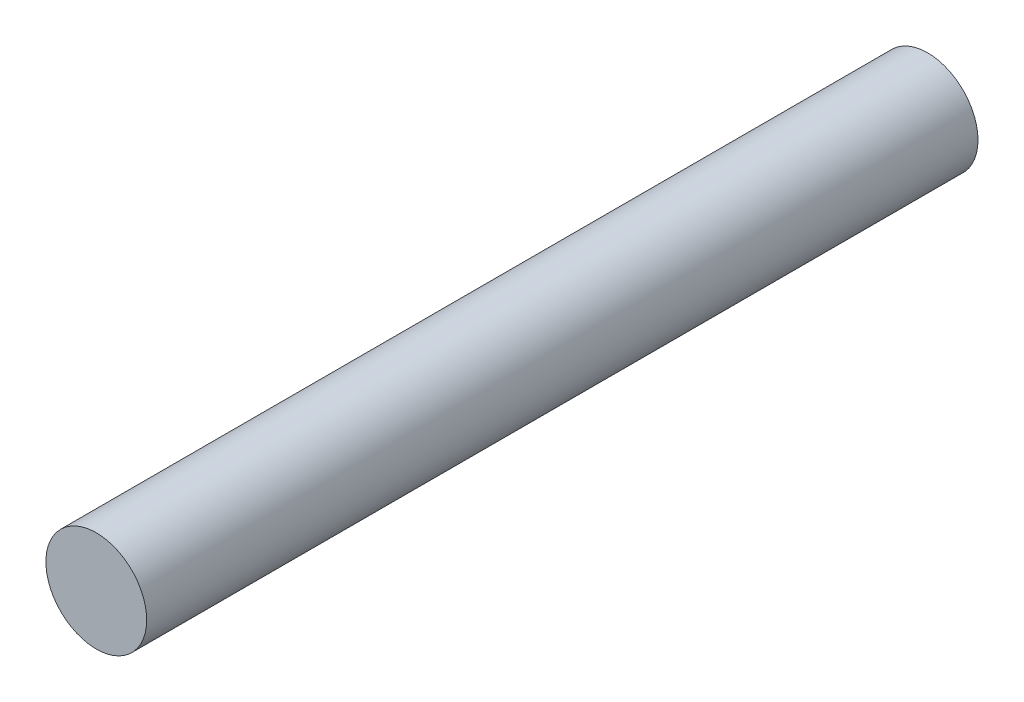
from build123d import *

# Parameters (mm, degrees)
SKETCH1_R           = 4
BOSS_EXTRUDE1_DEPTH = 66


with BuildPart() as part:
    # Sketch1 → Boss-Extrude1 (new body)
    with BuildSketch(Plane.XY):
        Circle(SKETCH1_R)
    extrude(amount=BOSS_EXTRUDE1_DEPTH)


solid = part.part
